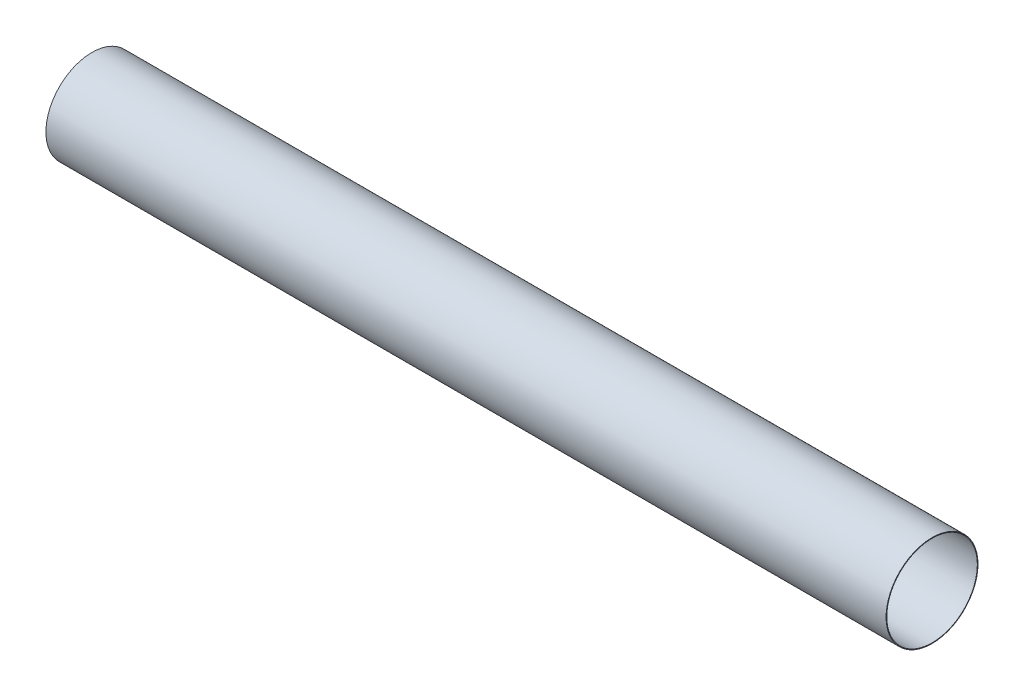
from build123d import *

# Parameters (mm, degrees)
SKIN_CROSS_SECTION_PROFILE_R   = 88.9
SKIN_CROSS_SECTION_PROFILE_R_2 = 87.63
CYLIDER_SKIN_EXTRUDE_DEPTH     = 1625.6


with BuildPart() as part:
    # Skin cross section profile → Cylider skin extrude (new body)
    with BuildSketch(Plane(origin=(0, 0, 0), x_dir=(0, -1, 0), z_dir=(1, 0, 0))):
        Circle(SKIN_CROSS_SECTION_PROFILE_R)
        Circle(SKIN_CROSS_SECTION_PROFILE_R_2, mode=Mode.SUBTRACT)
    extrude(amount=CYLIDER_SKIN_EXTRUDE_DEPTH)


solid = part.part
